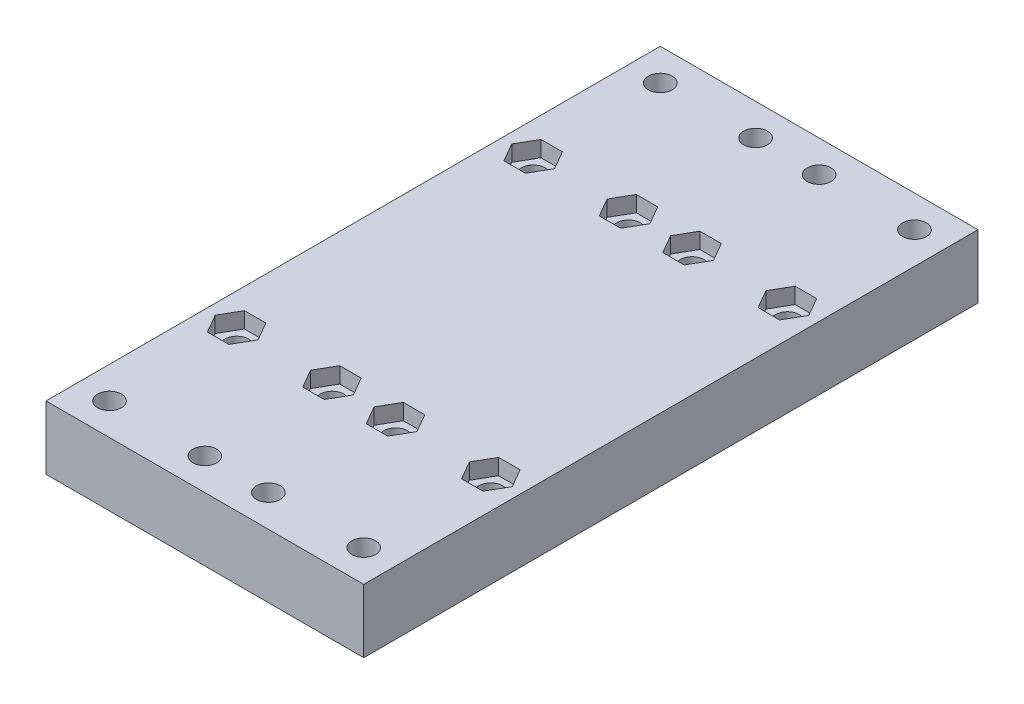
from build123d import *

# Parameters (mm, degrees)
SKETCH1_W                      = 60
SKETCH1_H                      = 116
BOSS_EXTRUDE1_DEPTH            = 12
CUT_EXTRUDE1_REACH             = 14
SKETCH2_R                      = 2.25
CUT_EXTRUDE1_DIRECTION_2_DEPTH = 1
CUT_EXTRUDE2_DEPTH             = 1
CUT_EXTRUDE2_DEPTH_BACK        = 3


with BuildPart() as part:
    # Sketch1 → Boss-Extrude1 (new body)
    with BuildSketch(Plane(origin=(0, 0, 0), x_dir=(1, 0, 0), z_dir=(0, 1, 0))):
        Rectangle(SKETCH1_W, SKETCH1_H)
    extrude(amount=BOSS_EXTRUDE1_DEPTH)

    # Sketch2 → Cut-Extrude1 (cut, up to next)
    with BuildSketch(Plane(origin=(0, 12, 0), x_dir=(1, 0, 0), z_dir=(0, 1, 0)), mode=Mode.PRIVATE) as cut_extrude1_sk1:
        with Locations((-24, 52)):
            Circle(SKETCH2_R)
    cut_extrude1_tool1 = extrude(cut_extrude1_sk1.sketch, amount=-CUT_EXTRUDE1_REACH, mode=Mode.PRIVATE) & part.part
    add(cut_extrude1_tool1.solids().sort_by_distance((-24, 12, -52))[0], mode=Mode.SUBTRACT)
    # Sketch2 → Cut-Extrude1 (cut, up to next)
    with BuildSketch(Plane(origin=(0, 12, 0), x_dir=(1, 0, 0), z_dir=(0, 1, 0)), mode=Mode.PRIVATE) as cut_extrude1_sk2:
        with Locations((-6, 52)):
            Circle(SKETCH2_R)
    cut_extrude1_tool2 = extrude(cut_extrude1_sk2.sketch, amount=-CUT_EXTRUDE1_REACH, mode=Mode.PRIVATE) & part.part
    add(cut_extrude1_tool2.solids().sort_by_distance((-6, 12, -52))[0], mode=Mode.SUBTRACT)
    # Sketch2 → Cut-Extrude1 (cut, up to next)
    with BuildSketch(Plane(origin=(0, 12, 0), x_dir=(1, 0, 0), z_dir=(0, 1, 0)), mode=Mode.PRIVATE) as cut_extrude1_sk3:
        with Locations((-24, 28)):
            Circle(SKETCH2_R)
    cut_extrude1_tool3 = extrude(cut_extrude1_sk3.sketch, amount=-CUT_EXTRUDE1_REACH, mode=Mode.PRIVATE) & part.part
    add(cut_extrude1_tool3.solids().sort_by_distance((-24, 12, -28))[0], mode=Mode.SUBTRACT)
    # Sketch2 → Cut-Extrude1 (cut, up to next)
    with BuildSketch(Plane(origin=(0, 12, 0), x_dir=(1, 0, 0), z_dir=(0, 1, 0)), mode=Mode.PRIVATE) as cut_extrude1_sk4:
        with Locations((-6, 28)):
            Circle(SKETCH2_R)
    cut_extrude1_tool4 = extrude(cut_extrude1_sk4.sketch, amount=-CUT_EXTRUDE1_REACH, mode=Mode.PRIVATE) & part.part
    add(cut_extrude1_tool4.solids().sort_by_distance((-6, 12, -28))[0], mode=Mode.SUBTRACT)
    # Sketch2 → Cut-Extrude1 (cut, up to next)
    with BuildSketch(Plane(origin=(0, 12, 0), x_dir=(1, 0, 0), z_dir=(0, 1, 0)), mode=Mode.PRIVATE) as cut_extrude1_sk5:
        with Locations((6, 28)):
            Circle(SKETCH2_R)
    cut_extrude1_tool5 = extrude(cut_extrude1_sk5.sketch, amount=-CUT_EXTRUDE1_REACH, mode=Mode.PRIVATE) & part.part
    add(cut_extrude1_tool5.solids().sort_by_distance((6, 12, -28))[0], mode=Mode.SUBTRACT)
    # Sketch2 → Cut-Extrude1 (cut, up to next)
    with BuildSketch(Plane(origin=(0, 12, 0), x_dir=(1, 0, 0), z_dir=(0, 1, 0)), mode=Mode.PRIVATE) as cut_extrude1_sk6:
        with Locations((24, 28)):
            Circle(SKETCH2_R)
    cut_extrude1_tool6 = extrude(cut_extrude1_sk6.sketch, amount=-CUT_EXTRUDE1_REACH, mode=Mode.PRIVATE) & part.part
    add(cut_extrude1_tool6.solids().sort_by_distance((24, 12, -28))[0], mode=Mode.SUBTRACT)
    # Sketch2 → Cut-Extrude1 (cut, up to next)
    with BuildSketch(Plane(origin=(0, 12, 0), x_dir=(1, 0, 0), z_dir=(0, 1, 0)), mode=Mode.PRIVATE) as cut_extrude1_sk7:
        with Locations((6, 52)):
            Circle(SKETCH2_R)
    cut_extrude1_tool7 = extrude(cut_extrude1_sk7.sketch, amount=-CUT_EXTRUDE1_REACH, mode=Mode.PRIVATE) & part.part
    add(cut_extrude1_tool7.solids().sort_by_distance((6, 12, -52))[0], mode=Mode.SUBTRACT)
    # Sketch2 → Cut-Extrude1 (cut, up to next)
    with BuildSketch(Plane(origin=(0, 12, 0), x_dir=(1, 0, 0), z_dir=(0, 1, 0)), mode=Mode.PRIVATE) as cut_extrude1_sk8:
        with Locations((24, 52)):
            Circle(SKETCH2_R)
    cut_extrude1_tool8 = extrude(cut_extrude1_sk8.sketch, amount=-CUT_EXTRUDE1_REACH, mode=Mode.PRIVATE) & part.part
    add(cut_extrude1_tool8.solids().sort_by_distance((24, 12, -52))[0], mode=Mode.SUBTRACT)
    # Sketch2 → Cut-Extrude1 (cut, up to next)
    with BuildSketch(Plane(origin=(0, 12, 0), x_dir=(1, 0, 0), z_dir=(0, 1, 0)), mode=Mode.PRIVATE) as cut_extrude1_sk9:
        with Locations((24, -52)):
            Circle(SKETCH2_R)
    cut_extrude1_tool9 = extrude(cut_extrude1_sk9.sketch, amount=-CUT_EXTRUDE1_REACH, mode=Mode.PRIVATE) & part.part
    add(cut_extrude1_tool9.solids().sort_by_distance((24, 12, 52))[0], mode=Mode.SUBTRACT)
    # Sketch2 → Cut-Extrude1 (cut, up to next)
    with BuildSketch(Plane(origin=(0, 12, 0), x_dir=(1, 0, 0), z_dir=(0, 1, 0)), mode=Mode.PRIVATE) as cut_extrude1_sk10:
        with Locations((6, -52)):
            Circle(SKETCH2_R)
    cut_extrude1_tool10 = extrude(cut_extrude1_sk10.sketch, amount=-CUT_EXTRUDE1_REACH, mode=Mode.PRIVATE) & part.part
    add(cut_extrude1_tool10.solids().sort_by_distance((6, 12, 52))[0], mode=Mode.SUBTRACT)
    # Sketch2 → Cut-Extrude1 (cut, up to next)
    with BuildSketch(Plane(origin=(0, 12, 0), x_dir=(1, 0, 0), z_dir=(0, 1, 0)), mode=Mode.PRIVATE) as cut_extrude1_sk11:
        with Locations((24, -28)):
            Circle(SKETCH2_R)
    cut_extrude1_tool11 = extrude(cut_extrude1_sk11.sketch, amount=-CUT_EXTRUDE1_REACH, mode=Mode.PRIVATE) & part.part
    add(cut_extrude1_tool11.solids().sort_by_distance((24, 12, 28))[0], mode=Mode.SUBTRACT)
    # Sketch2 → Cut-Extrude1 (cut, up to next)
    with BuildSketch(Plane(origin=(0, 12, 0), x_dir=(1, 0, 0), z_dir=(0, 1, 0)), mode=Mode.PRIVATE) as cut_extrude1_sk12:
        with Locations((6, -28)):
            Circle(SKETCH2_R)
    cut_extrude1_tool12 = extrude(cut_extrude1_sk12.sketch, amount=-CUT_EXTRUDE1_REACH, mode=Mode.PRIVATE) & part.part
    add(cut_extrude1_tool12.solids().sort_by_distance((6, 12, 28))[0], mode=Mode.SUBTRACT)
    # Sketch2 → Cut-Extrude1 (cut, up to next)
    with BuildSketch(Plane(origin=(0, 12, 0), x_dir=(1, 0, 0), z_dir=(0, 1, 0)), mode=Mode.PRIVATE) as cut_extrude1_sk13:
        with Locations((-6, -28)):
            Circle(SKETCH2_R)
    cut_extrude1_tool13 = extrude(cut_extrude1_sk13.sketch, amount=-CUT_EXTRUDE1_REACH, mode=Mode.PRIVATE) & part.part
    add(cut_extrude1_tool13.solids().sort_by_distance((-6, 12, 28))[0], mode=Mode.SUBTRACT)
    # Sketch2 → Cut-Extrude1 (cut, up to next)
    with BuildSketch(Plane(origin=(0, 12, 0), x_dir=(1, 0, 0), z_dir=(0, 1, 0)), mode=Mode.PRIVATE) as cut_extrude1_sk14:
        with Locations((-24, -28)):
            Circle(SKETCH2_R)
    cut_extrude1_tool14 = extrude(cut_extrude1_sk14.sketch, amount=-CUT_EXTRUDE1_REACH, mode=Mode.PRIVATE) & part.part
    add(cut_extrude1_tool14.solids().sort_by_distance((-24, 12, 28))[0], mode=Mode.SUBTRACT)
    # Sketch2 → Cut-Extrude1 (cut, up to next)
    with BuildSketch(Plane(origin=(0, 12, 0), x_dir=(1, 0, 0), z_dir=(0, 1, 0)), mode=Mode.PRIVATE) as cut_extrude1_sk15:
        with Locations((-6, -52)):
            Circle(SKETCH2_R)
    cut_extrude1_tool15 = extrude(cut_extrude1_sk15.sketch, amount=-CUT_EXTRUDE1_REACH, mode=Mode.PRIVATE) & part.part
    add(cut_extrude1_tool15.solids().sort_by_distance((-6, 12, 52))[0], mode=Mode.SUBTRACT)
    # Sketch2 → Cut-Extrude1 (cut, up to next)
    with BuildSketch(Plane(origin=(0, 12, 0), x_dir=(1, 0, 0), z_dir=(0, 1, 0)), mode=Mode.PRIVATE) as cut_extrude1_sk16:
        with Locations((-24, -52)):
            Circle(SKETCH2_R)
    cut_extrude1_tool16 = extrude(cut_extrude1_sk16.sketch, amount=-CUT_EXTRUDE1_REACH, mode=Mode.PRIVATE) & part.part
    add(cut_extrude1_tool16.solids().sort_by_distance((-24, 12, 52))[0], mode=Mode.SUBTRACT)

    # Sketch2 → Cut-Extrude1 direction 2 (cut)
    with BuildSketch(Plane(origin=(0, 12, 0), x_dir=(1, 0, 0), z_dir=(0, 1, 0))):
        with Locations((-24, 52)):
            Circle(SKETCH2_R)
        with Locations((-6, 52)):
            Circle(SKETCH2_R)
        with Locations((-24, 28)):
            Circle(SKETCH2_R)
        with Locations((-6, 28)):
            Circle(SKETCH2_R)
        with Locations((6, 28)):
            Circle(SKETCH2_R)
        with Locations((24, 28)):
            Circle(SKETCH2_R)
        with Locations((6, 52)):
            Circle(SKETCH2_R)
        with Locations((24, 52)):
            Circle(SKETCH2_R)
        with Locations((24, -52)):
            Circle(SKETCH2_R)
        with Locations((6, -52)):
            Circle(SKETCH2_R)
        with Locations((24, -28)):
            Circle(SKETCH2_R)
        with Locations((6, -28)):
            Circle(SKETCH2_R)
        with Locations((-6, -28)):
            Circle(SKETCH2_R)
        with Locations((-24, -28)):
            Circle(SKETCH2_R)
        with Locations((-6, -52)):
            Circle(SKETCH2_R)
        with Locations((-24, -52)):
            Circle(SKETCH2_R)
    extrude(amount=CUT_EXTRUDE1_DIRECTION_2_DEPTH, mode=Mode.SUBTRACT)

    # Sketch3 → Cut-Extrude2 (cut, two sides)
    with BuildSketch(Plane(origin=(0, 12, 0), x_dir=(1, 0, 0), z_dir=(0, 1, 0))) as cut_extrude2_sk:
        Polygon((-19.958548116, -28), (-21.979274058, -24.5), (-26.020725942, -24.5), (-28.041451884, -28), (-26.020725942, -31.5), (-21.979274058, -31.5), align=None)
        Polygon((-1.958548116, -28), (-3.979274058, -24.5), (-8.020725942, -24.5), (-10.041451884, -28), (-8.020725942, -31.5), (-3.979274058, -31.5), align=None)
        Polygon((3.979274058, -31.5), (1.958548116, -28), (3.979274058, -24.5), (8.020725942, -24.5), (10.041451884, -28), (8.020725942, -31.5), align=None)
        Polygon((21.979274058, -31.5), (19.958548116, -28), (21.979274058, -24.5), (26.020725942, -24.5), (28.041451884, -28), (26.020725942, -31.5), align=None)
        Polygon((26.020725942, 31.5), (21.979274058, 31.5), (19.958548116, 28), (21.979274058, 24.5), (26.020725942, 24.5), (28.041451884, 28), align=None)
        Polygon((8.020725942, 31.5), (3.979274058, 31.5), (1.958548116, 28), (3.979274058, 24.5), (8.020725942, 24.5), (10.041451884, 28), align=None)
        Polygon((-3.979274058, 31.5), (-1.958548116, 28), (-3.979274058, 24.5), (-8.020725942, 24.5), (-10.041451884, 28), (-8.020725942, 31.5), align=None)
        Polygon((-21.979274058, 31.5), (-19.958548116, 28), (-21.979274058, 24.5), (-26.020725942, 24.5), (-28.041451884, 28), (-26.020725942, 31.5), align=None)
    extrude(amount=CUT_EXTRUDE2_DEPTH, mode=Mode.SUBTRACT)
    extrude(cut_extrude2_sk.sketch, amount=-CUT_EXTRUDE2_DEPTH_BACK, mode=Mode.SUBTRACT)


solid = part.part
